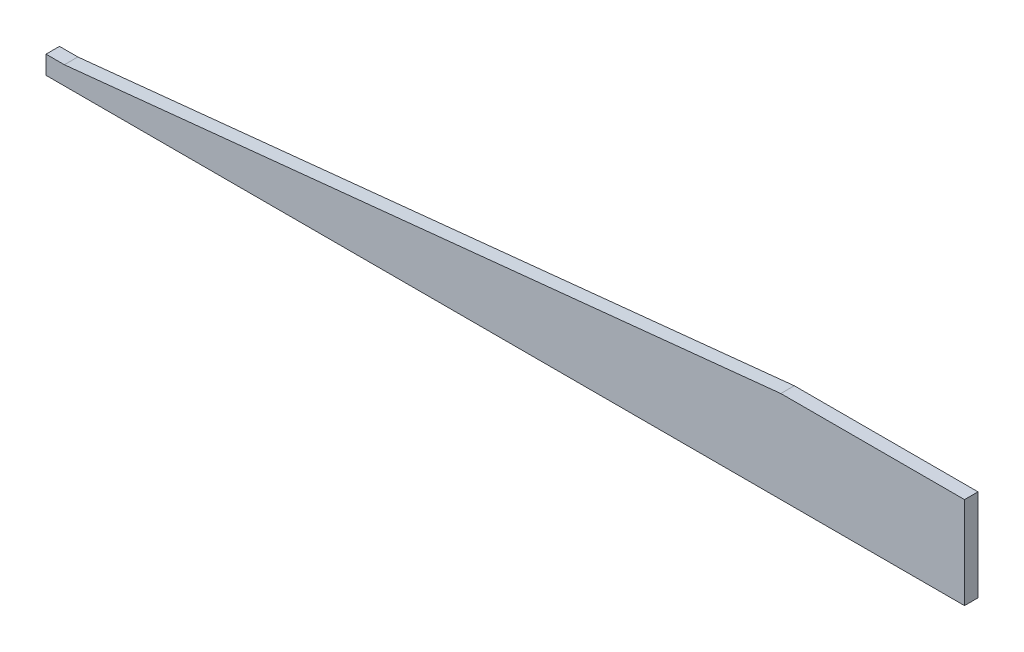
from build123d import *

# Parameters (mm, degrees)
BOSS_EXTRU_1_DEPTH = 22


with BuildPart() as part:
    # Esquisse1 → Boss.-Extru.1 (new body)
    with BuildSketch(Plane.XY):
        Polygon((30, 30), (1200, 150), (1500, 150), (1500, 0), (0, 0), (0, 30), align=None)
    extrude(amount=BOSS_EXTRU_1_DEPTH)


solid = part.part
